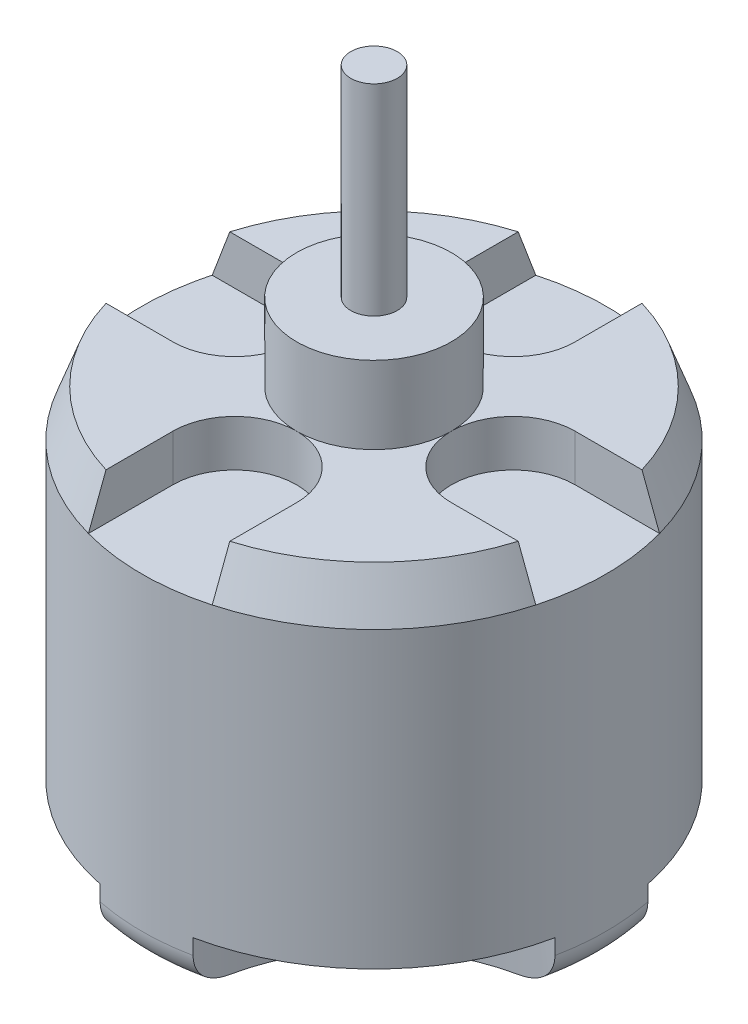
from build123d import *

# Parameters (mm, degrees)
CHANFREIN1_SIZE         = 3
CHANFREIN1_SIZE2        = 1.091910703
CONG_1_R                = 2
ENL_V_MAT_EXTRU_1_DEPTH = 3
ESQUISSE3_R             = 1.5
ENL_V_MAT_EXTRU_2_DEPTH = 3
ESQUISSE4_R             = 5
ESQUISSE4_R_2           = 1.5
ENL_V_MAT_EXTRU_3_DEPTH = 1


with BuildPart() as part:
    # Esquisse1 → Révolution1 (revolve)
    with BuildSketch(Plane.XY):
        Polygon((0, 23), (0, -20), (0, -22), (-1.5, -22), (-1.5, -20), (-15, -20), (-15, 5), (-5, 5), (-5, 10), (-1.5, 10), (-1.5, 23), align=None)
    revolve(axis=Axis((0, 23, 0), (0, -1, 0)))

    # Chanfrein1
    chanfrein1_edges = [part.edges().sort_by_distance(p)[0] for p in [
        (15, 5, 0),
    ]]
    chanfrein1_side = [part.faces().sort_by_distance(p)[0] for p in [
        (15, -7.5, 0),
    ]]
    chamfer(chanfrein1_edges, length=CHANFREIN1_SIZE, length2=CHANFREIN1_SIZE2, reference=chanfrein1_side[0])

    # Congé1
    cong_1_edges = [part.edges().sort_by_distance(p)[0] for p in [
        (15, -20, 0),
    ]]
    fillet(cong_1_edges, radius=CONG_1_R)

    # Esquisse2 → Enlèv. mat.-Extru.1 (cut)
    with BuildSketch(Plane(origin=(0, 5, 0), x_dir=(1, 0, 0), z_dir=(0, 1, 0))):
        with BuildLine():
            Line((-4, 9), (-4, 19))
            Line((-4, 19), (4, 19))
            Line((4, 19), (4, 9))
            ThreePointArc((4, 9), (0, 5), (-4, 9))
        make_face()
        with BuildLine():
            Line((9, 4), (19, 4))
            Line((19, 4), (19, -4))
            Line((19, -4), (9, -4))
            ThreePointArc((9, -4), (5, 0), (9, 4))
        make_face()
        with BuildLine():
            Line((4, -9), (4, -19))
            Line((4, -19), (-4, -19))
            Line((-4, -19), (-4, -9))
            ThreePointArc((-4, -9), (0, -5), (4, -9))
        make_face()
        with BuildLine():
            Line((-9, -4), (-19, -4))
            Line((-19, -4), (-19, 4))
            Line((-19, 4), (-9, 4))
            ThreePointArc((-9, 4), (-5, 0), (-9, -4))
        make_face()
    extrude(amount=-ENL_V_MAT_EXTRU_1_DEPTH, mode=Mode.SUBTRACT)

    # Esquisse3 → Enlèv. mat.-Extru.2 (cut)
    with BuildSketch(Plane.XZ.offset(20)):
        with Locations((0, 9)):
            Circle(ESQUISSE3_R)
        with Locations((0, -9)):
            Circle(ESQUISSE3_R)
        with Locations((9, 0)):
            Circle(ESQUISSE3_R)
        with Locations((-9, 0)):
            Circle(ESQUISSE3_R)
        with BuildLine():
            ThreePointArc((-15, 3), (-6.514718626, 6.514718626), (-3, 15))
            ThreePointArc((-3, 15), (-12.991965185, 12.991965185), (-15, 3))
        make_face()
        with BuildLine():
            ThreePointArc((3, 15), (6.514718626, 6.514718626), (15, 3))
            ThreePointArc((15, 3), (12.889510499, 12.889510499), (3, 15))
        make_face()
        with BuildLine():
            ThreePointArc((15, -3), (6.514718626, -6.514718626), (3, -15))
            ThreePointArc((3, -15), (12.652903184, -12.652903184), (15, -3))
        make_face()
        with BuildLine():
            ThreePointArc((-15, -3), (-6.514718626, -6.514718626), (-3, -15))
            ThreePointArc((-3, -15), (-12.726788918, -12.726788918), (-15, -3))
        make_face()
    extrude(amount=-ENL_V_MAT_EXTRU_2_DEPTH, mode=Mode.SUBTRACT)

    # Esquisse4 → Enlèv. mat.-Extru.3 (cut)
    with BuildSketch(Plane.XZ.offset(20)):
        with Locations(Location((0, 0, 0), (0, 0, 180))):
            Circle(ESQUISSE4_R)
        with Locations(Location((0, 0, 0), (0, 0, 180))):
            Circle(ESQUISSE4_R_2, mode=Mode.SUBTRACT)
    extrude(amount=-ENL_V_MAT_EXTRU_3_DEPTH, mode=Mode.SUBTRACT)


solid = part.part
